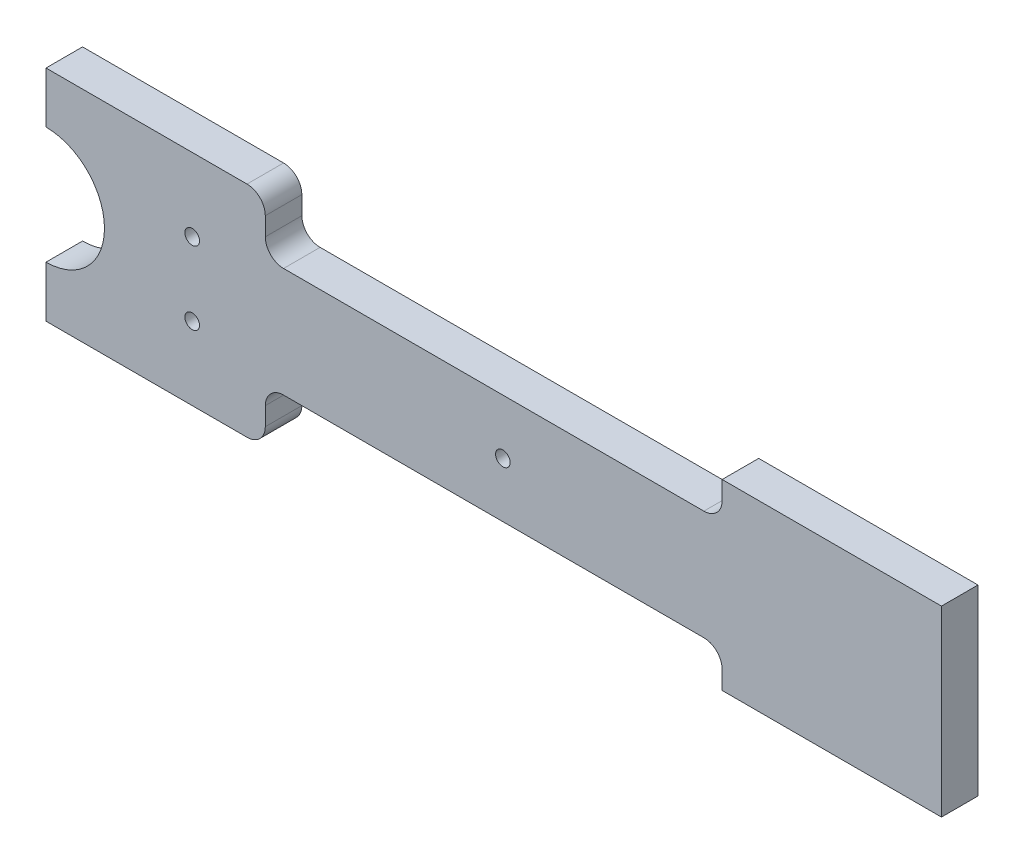
from build123d import *

# Parameters (mm, degrees)
BOSS_EXTRUDE1_DEPTH = 10
SKETCH2_R           = 2
SKETCH2_R_2         = 16
CUT_EXTRUDE1_DEPTH  = 11
FILLET1_R           = 5
SKETCH3_R           = 2
CUT_EXTRUDE2_DEPTH  = 11
SKETCH4_W           = 10
SKETCH4_H           = 60
CUT_EXTRUDE3_DEPTH  = 246
SKETCH5_R           = 2
CUT_EXTRUDE4_DEPTH  = 12


with BuildPart() as part:
    # Sketch1 → Boss-Extrude1 (new body)
    with BuildSketch(Plane.XY):
        Polygon((245, 5), (245, 55), (185, 55), (185, 45), (60, 45), (60, 60), (-60, 60), (-60, 45), (-185, 45), (-185, 55), (-245, 55), (-245, 5), (-185, 5), (-185, 15), (-60, 15), (-60, 0), (60, 0), (60, 15), (185, 15), (185, 5), align=None)
    extrude(amount=BOSS_EXTRUDE1_DEPTH)

    # Sketch2 → Cut-Extrude1 (cut, through all)
    with BuildSketch(Plane.XY.offset(10)):
        with Locations((40, 20)):
            Circle(SKETCH2_R)
        with Locations((40, 40)):
            Circle(SKETCH2_R)
        with Locations((-40, 40)):
            Circle(SKETCH2_R)
        with Locations((-40, 20)):
            Circle(SKETCH2_R)
        with Locations((0, 30)):
            Circle(SKETCH2_R_2)
    extrude(amount=-CUT_EXTRUDE1_DEPTH, mode=Mode.SUBTRACT)

    # Fillet1
    fillet1_edges = [part.edges().sort_by_distance(p)[0] for p in [
        (185, 15, 5),
        (60, 15, 5),
        (60, 0, 5),
        (-60, 0, 5),
        (-60, 15, 5),
        (-185, 15, 5),
        (-185, 45, 5),
        (-60, 45, 5),
        (-60, 60, 5),
        (60, 60, 5),
        (60, 45, 5),
        (185, 45, 5),
    ]]
    fillet(fillet1_edges, radius=FILLET1_R)

    # Sketch3 → Cut-Extrude2 (cut, through all)
    with BuildSketch(Plane.XY.offset(10)):
        with Locations((-125, 30)):
            Circle(SKETCH3_R)
        with Locations((125, 30)):
            Circle(SKETCH3_R)
    extrude(amount=-CUT_EXTRUDE2_DEPTH, mode=Mode.SUBTRACT)

    # Sketch4 → Cut-Extrude3 (cut, through all)
    with BuildSketch(Plane(origin=(0, 0, 0), x_dir=(0, 0, -1), z_dir=(1, 0, 0))):
        with Locations((-5, 30)):
            Rectangle(SKETCH4_W, SKETCH4_H)
    extrude(amount=-CUT_EXTRUDE3_DEPTH, mode=Mode.SUBTRACT)

    # Sketch5 → Cut-Extrude4 (cut)
    with BuildSketch(Plane.ZY):
        with Locations((5, 53)):
            Circle(SKETCH5_R)
        with Locations((5, 7)):
            Circle(SKETCH5_R)
    extrude(amount=-CUT_EXTRUDE4_DEPTH, mode=Mode.SUBTRACT)


solid = part.part
